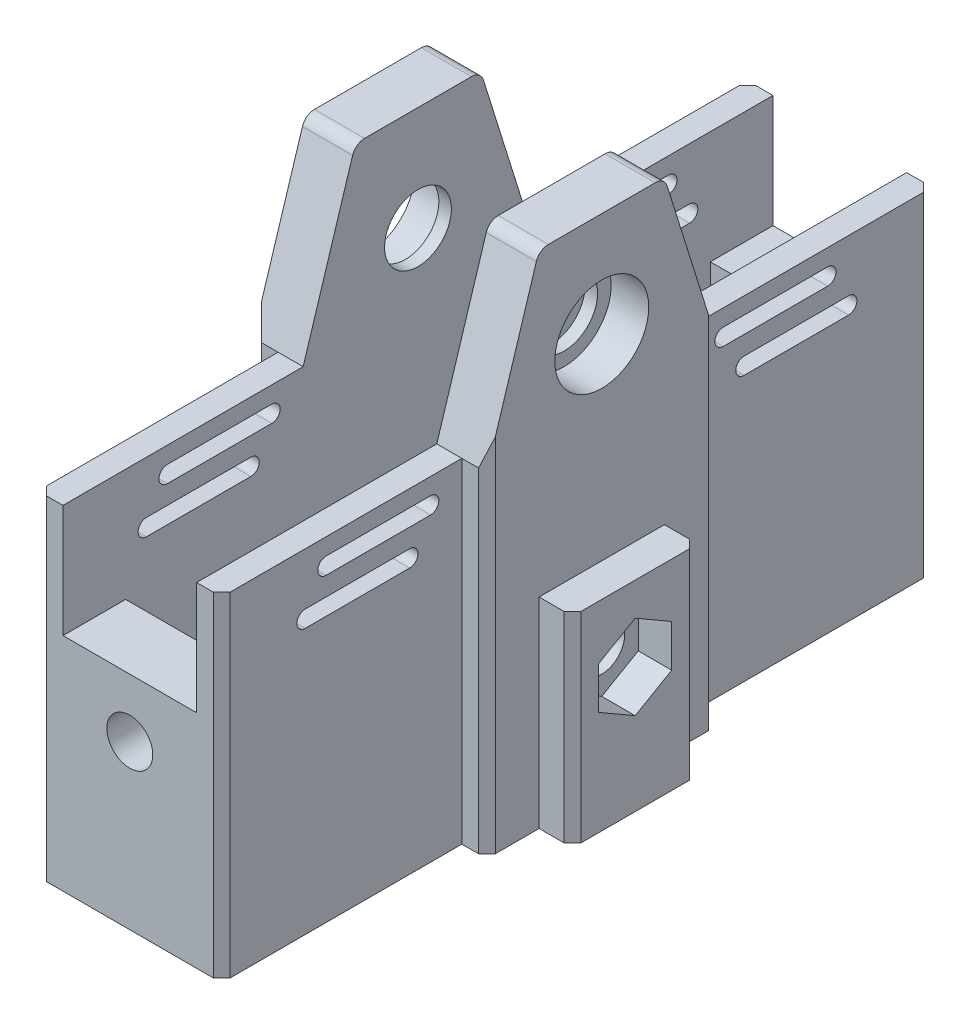
from build123d import *

# Parameters (mm, degrees)
BOSS_EXTRUDE1_DEPTH = 56
SKETCH5_W           = 32
SKETCH5_H           = 107
CUT_EXTRUDE2_DEPTH  = 171
SKETCH6_R           = 11.25
CUT_EXTRUDE3_DEPTH  = 57
SKETCH7_W           = 32
SKETCH7_H           = 15
BOSS_EXTRUDE2_DEPTH = 40
SKETCH9_R           = 5.5
CUT_EXTRUDE5_DEPTH  = 171
CUT_EXTRUDE6_DEPTH  = 57
CUT_EXTRUDE13_REACH = 82
SKETCH21_W          = 5.911313501
SKETCH21_H          = 57.5
SKETCH21_W_2        = 6
SKETCH23_R          = 11.25
BOSS_EXTRUDE3_DEPTH = 3
SKETCH26_R          = 11.25
BOSS_EXTRUDE5_DEPTH = 3
SKETCH28_R          = 8
CUT_EXTRUDE16_DEPTH = 47
SKETCH29_W          = 30
SKETCH29_H          = 48
BOSS_EXTRUDE6_DEPTH = 8
CUT_EXTRUDE18_DEPTH = 8
SKETCH32_R          = 5.5
CUT_EXTRUDE19_DEPTH = 12
CHAMFER1_SIZE       = 2
SKETCH34_W          = 20
SKETCH34_H          = 15
CUT_EXTRUDE20_DEPTH = 13
FILLET1_R           = 3
FILLET2_R           = 3


with BuildPart() as part:
    # Sketch1 → Boss-Extrude1 (new body)
    with BuildSketch(Plane(origin=(0, 0, 0), x_dir=(0, 0, -1), z_dir=(1, 0, 0))):
        Polygon((0, 0), (0, 80), (57.5, 80), (70, 120), (100, 120), (112.5, 80), (170, 80), (170, 0), align=None)
    extrude(amount=BOSS_EXTRUDE1_DEPTH)

    # Sketch5 → Cut-Extrude2 (cut, through all)
    with BuildSketch(Plane(origin=(0, 0, -170), x_dir=(-1, 0, 0), z_dir=(0, 0, -1))):
        with Locations((-28, 66.5)):
            Rectangle(SKETCH5_W, SKETCH5_H)
    extrude(amount=-CUT_EXTRUDE2_DEPTH, mode=Mode.SUBTRACT)

    # Sketch6 → Cut-Extrude3 (cut, through all)
    with BuildSketch(Plane(origin=(56, 0, 0), x_dir=(0, 0, -1), z_dir=(1, 0, 0))):
        with Locations((85, 95)):
            Circle(SKETCH6_R)
    extrude(amount=-CUT_EXTRUDE3_DEPTH, mode=Mode.SUBTRACT)

    # Sketch7 → Boss-Extrude2 (add)
    with BuildSketch(Plane(origin=(0, 13, 0), x_dir=(1, 0, 0), z_dir=(0, 1, 0))):
        with Locations((28, 162.5)):
            Rectangle(SKETCH7_W, SKETCH7_H)
        with Locations((28, 7.5)):
            Rectangle(SKETCH7_W, SKETCH7_H)
    extrude(amount=BOSS_EXTRUDE2_DEPTH)

    # Sketch9 → Cut-Extrude5 (cut, through all)
    with BuildSketch(Plane(origin=(0, 0, -170), x_dir=(-1, 0, 0), z_dir=(0, 0, -1))):
        with Locations((-28, 39)):
            Circle(SKETCH9_R)
    extrude(amount=-CUT_EXTRUDE5_DEPTH, mode=Mode.SUBTRACT)

    # Sketch10 → Cut-Extrude6 (cut, through all)
    with BuildSketch(Plane.ZY):
        with BuildLine():
            Line((-120, 76), (-145, 76))
            ThreePointArc((-145, 76), (-147, 74), (-145, 72))
            Line((-145, 72), (-120, 72))
            ThreePointArc((-120, 72), (-118, 74), (-120, 76))
        make_face()
        with BuildLine():
            Line((-125, 67.502941686), (-150, 67.502941686))
            ThreePointArc((-150, 67.502941686), (-152, 65.502941686), (-150, 63.502941686))
            Line((-150, 63.502941686), (-125, 63.502941686))
            ThreePointArc((-125, 63.502941686), (-123, 65.502941686), (-125, 67.502941686))
        make_face()
        with BuildLine():
            ThreePointArc((-25, 76), (-23, 74), (-25, 72))
            Line((-25, 72), (-50, 72))
            ThreePointArc((-50, 72), (-52, 74), (-50, 76))
            Line((-50, 76), (-25, 76))
        make_face()
        with BuildLine():
            ThreePointArc((-20, 67.502941686), (-18, 65.502941686), (-20, 63.502941686))
            Line((-20, 63.502941686), (-45, 63.502941686))
            ThreePointArc((-45, 63.502941686), (-47, 65.502941686), (-45, 67.502941686))
            Line((-45, 67.502941686), (-20, 67.502941686))
        make_face()
    extrude(amount=-CUT_EXTRUDE6_DEPTH, mode=Mode.SUBTRACT)

    # Sketch21 → Cut-Extrude13 (cut, up to next)
    with BuildSketch(Plane(origin=(0, 80, 0), x_dir=(1, 0, 0), z_dir=(0, 1, 0)), mode=Mode.PRIVATE) as cut_extrude13_sk1:
        with Locations((2.955656751, 141.25)):
            Rectangle(SKETCH21_W, SKETCH21_H)
    cut_extrude13_tool1 = extrude(cut_extrude13_sk1.sketch, amount=-CUT_EXTRUDE13_REACH, mode=Mode.PRIVATE) & part.part
    add(cut_extrude13_tool1.solids().sort_by_distance((2.955657, 80, -141.25))[0], mode=Mode.SUBTRACT)
    # Sketch21 → Cut-Extrude13 (cut, up to next)
    with BuildSketch(Plane(origin=(0, 80, 0), x_dir=(1, 0, 0), z_dir=(0, 1, 0)), mode=Mode.PRIVATE) as cut_extrude13_sk2:
        with Locations((3, 28.75)):
            Rectangle(SKETCH21_W_2, SKETCH21_H)
    cut_extrude13_tool2 = extrude(cut_extrude13_sk2.sketch, amount=-CUT_EXTRUDE13_REACH, mode=Mode.PRIVATE) & part.part
    add(cut_extrude13_tool2.solids().sort_by_distance((3, 80, -28.75))[0], mode=Mode.SUBTRACT)
    # Sketch21 → Cut-Extrude13 (cut, up to next)
    with BuildSketch(Plane(origin=(0, 80, 0), x_dir=(1, 0, 0), z_dir=(0, 1, 0)), mode=Mode.PRIVATE) as cut_extrude13_sk3:
        with Locations((53.04434325, 141.25)):
            Rectangle(SKETCH21_W, SKETCH21_H)
    cut_extrude13_tool3 = extrude(cut_extrude13_sk3.sketch, amount=-CUT_EXTRUDE13_REACH, mode=Mode.PRIVATE) & part.part
    add(cut_extrude13_tool3.solids().sort_by_distance((53.044343, 80, -141.25))[0], mode=Mode.SUBTRACT)
    # Sketch21 → Cut-Extrude13 (cut, up to next)
    with BuildSketch(Plane(origin=(0, 80, 0), x_dir=(1, 0, 0), z_dir=(0, 1, 0)), mode=Mode.PRIVATE) as cut_extrude13_sk4:
        with Locations((53, 28.75)):
            Rectangle(SKETCH21_W_2, SKETCH21_H)
    cut_extrude13_tool4 = extrude(cut_extrude13_sk4.sketch, amount=-CUT_EXTRUDE13_REACH, mode=Mode.PRIVATE) & part.part
    add(cut_extrude13_tool4.solids().sort_by_distance((53, 80, -28.75))[0], mode=Mode.SUBTRACT)

    # Sketch23 → Boss-Extrude3 (add)
    with BuildSketch(Plane(origin=(12, 0, 0), x_dir=(0, 0, -1), z_dir=(1, 0, 0))):
        with Locations((85, 95)):
            Circle(SKETCH23_R)
    extrude(amount=-BOSS_EXTRUDE3_DEPTH)


with BuildPart() as body_2:
    # Sketch26 → Boss-Extrude5 (new body)
    with BuildSketch(Plane.ZY.offset(-44)):
        with Locations((-85, 95)):
            Circle(SKETCH26_R)
    extrude(amount=-BOSS_EXTRUDE5_DEPTH)


with BuildPart() as cut_extrude16_tool:
    # Sketch28 → Cut-Extrude16 (new body)
    with BuildSketch(Plane.ZY.offset(-9)):
        with Locations((-85, 95)):
            Circle(SKETCH28_R)
    extrude(amount=-CUT_EXTRUDE16_DEPTH)


with BuildPart() as part_1:
    add(part.part)

    # Cut-Extrude16: cut by cut_extrude16_tool
    add(cut_extrude16_tool.part, mode=Mode.SUBTRACT)

    # Sketch29 → Boss-Extrude6 (add)
    with BuildSketch(Plane(origin=(56, 0, 0), x_dir=(0, 0, -1), z_dir=(1, 0, 0))):
        with Locations((85, 24)):
            Rectangle(SKETCH29_W, SKETCH29_H)
    boss_extrude6 = extrude(amount=BOSS_EXTRUDE6_DEPTH)

    # Sketch31 → Cut-Extrude18 (cut)
    with BuildSketch(Plane(origin=(64, 0, 0), x_dir=(0, 0, -1), z_dir=(1, 0, 0))):
        Polygon((76.25, 24.948185145), (85, 19.896370289), (93.75, 24.948185145), (93.75, 35.051814855), (85, 40.103629711), (76.25, 35.051814855), align=None)
        Polygon((70, 0), (70, 48), (100, 48), (100, 0), (112.5, 0), (112.5, 80), (100, 120), (70, 120), (57.5, 80), (57.5, 0), align=None)
    cut_extrude18 = extrude(amount=-CUT_EXTRUDE18_DEPTH, mode=Mode.SUBTRACT)

    # Sketch32 → Cut-Extrude19 (cut)
    with BuildSketch(Plane(origin=(56, 0, 0), x_dir=(0, 0, -1), z_dir=(1, 0, 0))):
        with Locations((85, 30)):
            Circle(SKETCH32_R)
    cut_extrude19 = extrude(amount=-CUT_EXTRUDE19_DEPTH, mode=Mode.SUBTRACT)

    # Mirror3: Boss-Extrude6 across plane
    add(boss_extrude6.mirror(Plane.ZY.offset(-28)))

    # Mirror4: Cut-Extrude18, Cut-Extrude19 across plane
    add(cut_extrude18.mirror(Plane.ZY.offset(-28)), mode=Mode.SUBTRACT)
    add(cut_extrude19.mirror(Plane.ZY.offset(-28)), mode=Mode.SUBTRACT)

    # Chamfer1
    chamfer1_edges = [part_1.edges().sort_by_distance(p)[0] for p in [
        (56, 40, -112.5),
        (50.088686499, 40, -170),
        (56, 40, -57.5),
        (50, 40, 0),
        (0, 40, -57.5),
        (6, 40, 0),
        (0, 40, -112.5),
        (5.911313501, 40, -170),
        (64, 24, -100),
        (64, 24, -70),
        (-8, 24, -70),
        (-8, 24, -100),
    ]]
    chamfer(chamfer1_edges, length=CHAMFER1_SIZE)

    # Sketch34 → Cut-Extrude20 (cut)
    with BuildSketch(Plane(origin=(0, 13, 0), x_dir=(1, 0, 0), z_dir=(0, 1, 0))):
        with Locations((28.591981111, 130)):
            Rectangle(SKETCH34_W, SKETCH34_H)
        with Locations((28.591981111, 40)):
            Rectangle(SKETCH34_W, SKETCH34_H)
    extrude(amount=-CUT_EXTRUDE20_DEPTH, mode=Mode.SUBTRACT)

    # Fillet1
    fillet1_edges = [part_1.edges().sort_by_distance(p)[0] for p in [
        (18.591981111, 6.5, -122.5),
        (18.591981111, 6.5, -137.5),
        (38.591981111, 6.5, -137.5),
        (38.591981111, 6.5, -122.5),
        (38.591981111, 6.5, -47.5),
        (38.591981111, 6.5, -32.5),
        (18.591981111, 6.5, -32.5),
        (18.591981111, 6.5, -47.5),
    ]]
    fillet(fillet1_edges, radius=FILLET1_R)

    # Fillet2
    fillet2_edges = [part_1.edges().sort_by_distance(p)[0] for p in [
        (50, 120, -70),
        (50, 120, -100),
        (6, 120, -70),
        (6, 120, -100),
    ]]
    fillet(fillet2_edges, radius=FILLET2_R)


with BuildPart() as body_2_1:
    add(body_2.part)

    # Cut-Extrude16: cut by cut_extrude16_tool
    add(cut_extrude16_tool.part, mode=Mode.SUBTRACT)


solid = Compound([part_1.part, body_2_1.part])
